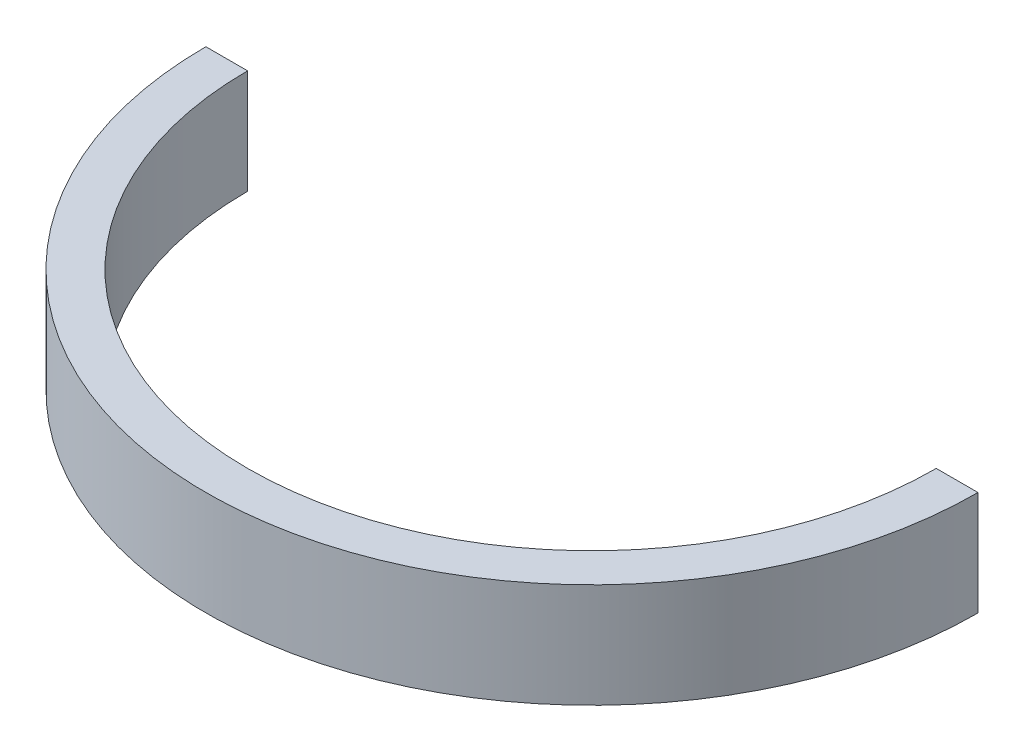
from build123d import *

# Parameters (mm, degrees)
EXTRUDE_1_DEPTH = 20


with BuildPart() as part:
    # 草图1 → 凸台-拉伸1 (new body)
    with BuildSketch(Plane(origin=(0, 0, 0), x_dir=(1, 0, 0), z_dir=(0, 1, 0))):
        with BuildLine():
            Line((-74, 0), (-66, 0))
            ThreePointArc((-66, 0), (0, -66), (66, 0))
            Line((66, 0), (74, 0))
            ThreePointArc((74, 0), (0, -74), (-74, 0))
        make_face()
    extrude(amount=EXTRUDE_1_DEPTH)


solid = part.part
